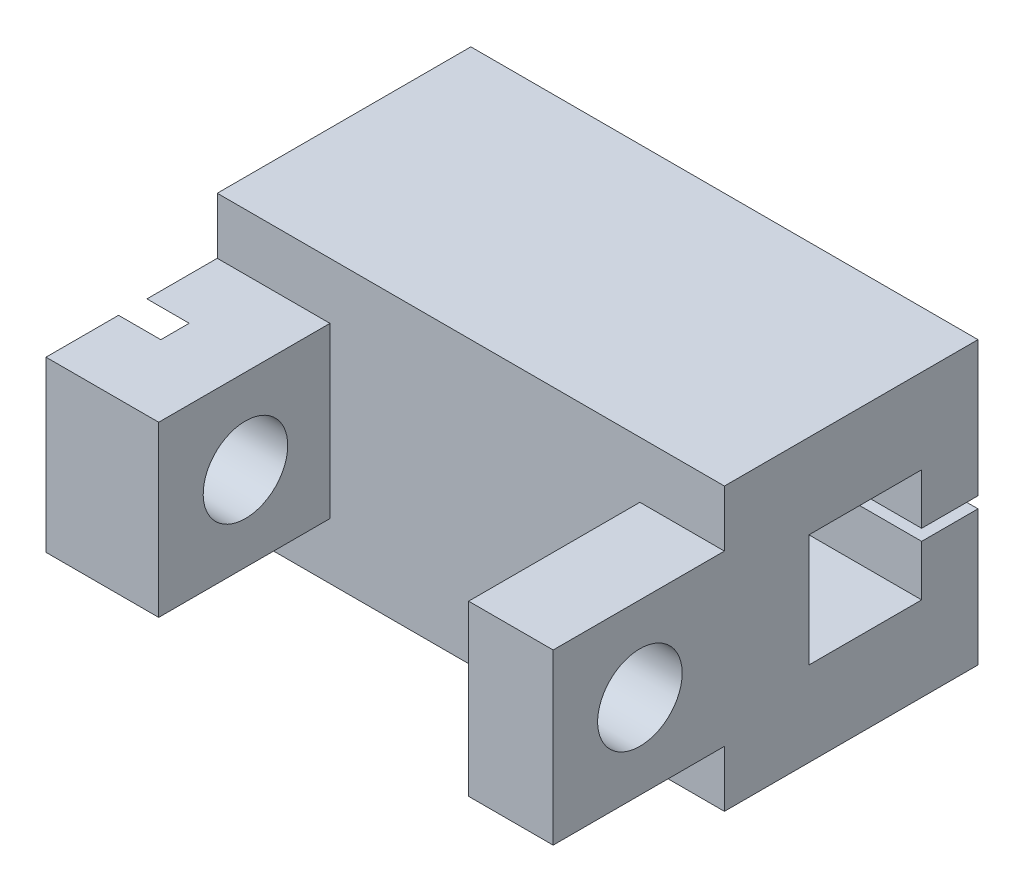
from build123d import *

# Parameters (mm, degrees)
CROQUIS1_W              = 18
CROQUIS1_H              = 10
SALIENTE_EXTRUIR1_DEPTH = 3
CROQUIS2_W              = 6.078202003
CROQUIS2_H              = 6
CROQUIS2_R              = 1.5
SALIENTE_EXTRUIR2_DEPTH = 3
SALIENTE_EXTRUIR3_START = -18
CROQUIS2_2_W            = 6.078202003
CROQUIS2_2_H            = 6
CROQUIS2_2_R            = 1.5
SALIENTE_EXTRUIR3_DEPTH = 4
CORTAR_EXTRUIR1_DEPTH   = 1.5
SALIENTE_EXTRUIR4_DEPTH = 18


with BuildPart() as part:
    # Croquis1 → Saliente-Extruir1 (new body)
    with BuildSketch(Plane.XY):
        with Locations((1.07264213, -3.260188088)):
            Rectangle(CROQUIS1_W, CROQUIS1_H)
    extrude(amount=SALIENTE_EXTRUIR1_DEPTH)

    # Croquis2 → Saliente-Extruir2 (add)
    with BuildSketch(Plane(origin=(10.07264213, 0, 0), x_dir=(0, 0, -1), z_dir=(1, 0, 0))):
        with Locations((-6.039101002, -3.260188088)):
            Rectangle(CROQUIS2_W, CROQUIS2_H)
        with Locations((-5.99926787, -3.260188088)):
            Circle(CROQUIS2_R, mode=Mode.SUBTRACT)
    extrude(amount=-SALIENTE_EXTRUIR2_DEPTH)

    # Croquis2_2 → Saliente-Extruir3 (add)
    with BuildSketch(Plane(origin=(10.07264213, 0, 0), x_dir=(0, 0, -1), z_dir=(1, 0, 0)).offset(SALIENTE_EXTRUIR3_START)):
        with Locations((-6.039101002, -3.260188088)):
            Rectangle(CROQUIS2_2_W, CROQUIS2_2_H)
        with Locations((-5.99926787, -3.260188088)):
            Circle(CROQUIS2_2_R, mode=Mode.SUBTRACT)
    extrude(amount=SALIENTE_EXTRUIR3_DEPTH)

    # Croquis3 → Cortar-Extruir1 (cut)
    with BuildSketch(Plane.ZY.offset(7.92735787)):
        Polygon((5.99926787, -6.551084622), (8.84926787, -4.905636355), (8.84926787, -1.614739821), (5.99926787, 0.030708447), (3.14926787, -1.614739821), (3.14926787, -4.905636355), align=None)
    extrude(amount=-CORTAR_EXTRUIR1_DEPTH, mode=Mode.SUBTRACT)

    # Croquis4 → Saliente-Extruir4 (add)
    with BuildSketch(Plane(origin=(10.07264213, 0, 0), x_dir=(0, 0, -1), z_dir=(1, 0, 0))):
        Polygon((4, -1.260188088), (4, -3.060188088), (6, -3.060188088), (6, -1.260188088), (6, 1.739811912), (0, 1.739811912), (0, -1.260188088), align=None)
        Polygon((0, -8.260188088), (6, -8.260188088), (6, -5.260188088), (6, -3.460188088), (4, -3.460188088), (4, -5.260188088), (0, -5.260188088), align=None)
    extrude(amount=-SALIENTE_EXTRUIR4_DEPTH)


solid = part.part
